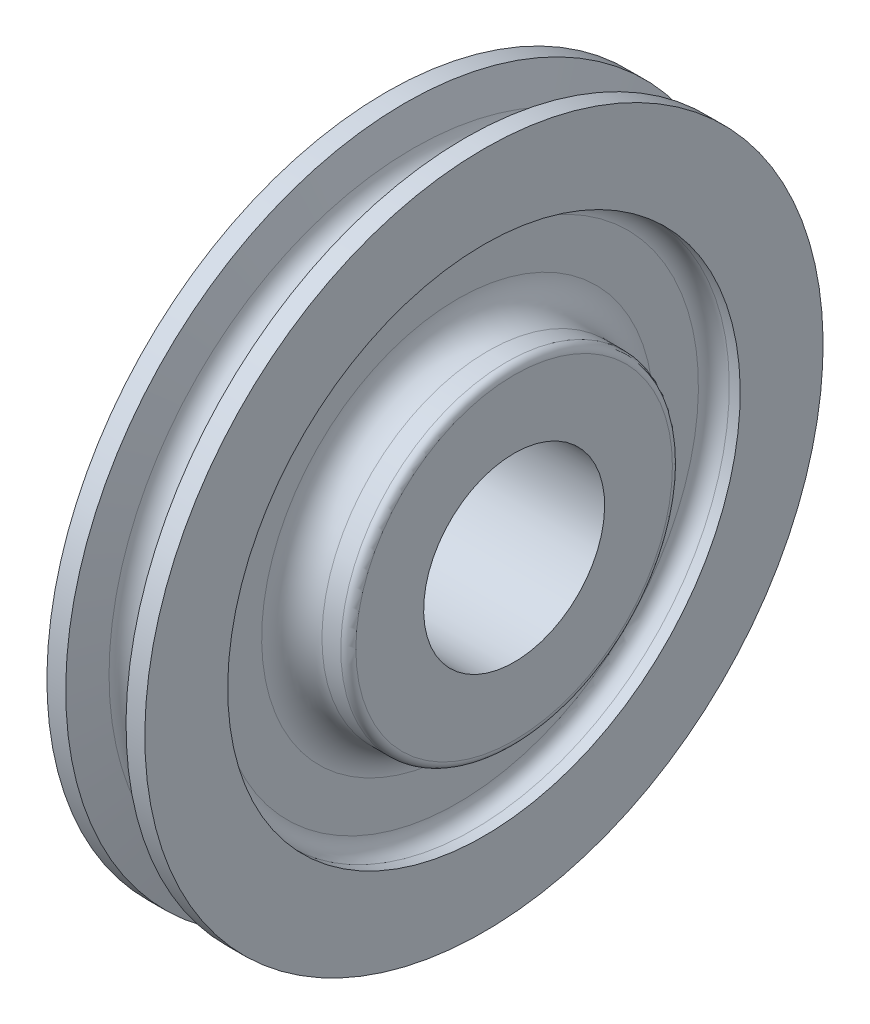
from build123d import *

# Parameters (mm, degrees)
SKETCH2_R          = 19.0627
CUT_EXTRUDE1_DEPTH = 34.3375


with BuildPart() as part:
    # Sketch1 → Revolve1 (revolve)
    with BuildSketch(Plane.XY):
        with BuildLine():
            Line((16.66875, 0), (-16.66875, 0))
            Line((-16.66875, 0), (-16.66875, 33.3375))
            ThreePointArc((-16.66875, 33.3375), (-16.203782015, 34.460032015), (-15.08125, 34.925))
            Line((-15.08125, 34.925), (-11.1125, 34.925))
            ThreePointArc((-11.1125, 34.925), (-6.622371939, 36.784871939), (-4.7625, 41.275))
            Line((-4.7625, 41.275), (-4.7625, 50.7238))
            ThreePointArc((-4.7625, 50.7238), (-5.714754433, 53.022745567), (-8.0137, 53.975))
            Line((-8.0137, 53.975), (-10.3124, 53.975))
            Line((-10.3124, 53.975), (-10.3124, 71.43115))
            Line((-10.3124, 71.43115), (-6.35, 71.43115))
            Line((-6.35, 71.43115), (-4.640755559, 64.017549491))
            ThreePointArc((-4.640755559, 64.017549491), (0, 60.325), (4.640755559, 64.017549491))
            Line((4.640755559, 64.017549491), (6.35, 71.43115))
            Line((6.35, 71.43115), (10.3124, 71.43115))
            Line((10.3124, 71.43115), (10.3124, 53.975))
            Line((10.3124, 53.975), (8.0137, 53.975))
            ThreePointArc((8.0137, 53.975), (5.714754433, 53.022745567), (4.7625, 50.7238))
            Line((4.7625, 50.7238), (4.7625, 41.275))
            ThreePointArc((4.7625, 41.275), (6.622371939, 36.784871939), (11.1125, 34.925))
            Line((11.1125, 34.925), (15.08125, 34.925))
            ThreePointArc((15.08125, 34.925), (16.203782015, 34.460032015), (16.66875, 33.3375))
            Line((16.66875, 33.3375), (16.66875, 0))
        make_face()
    revolve(axis=Axis((16.66875, 0, 0), (-1, 0, 0)))

    # Sketch2 → Cut-Extrude1 (cut, through all)
    with BuildSketch(Plane(origin=(16.66875, 0, 0), x_dir=(0, 0, -1), z_dir=(1, 0, 0))):
        with Locations(Location((0, 0, 0), (0, 0, 90))):  # turned: the seam where the file's is
            Circle(SKETCH2_R)
    extrude(amount=-CUT_EXTRUDE1_DEPTH, mode=Mode.SUBTRACT)


solid = part.part
